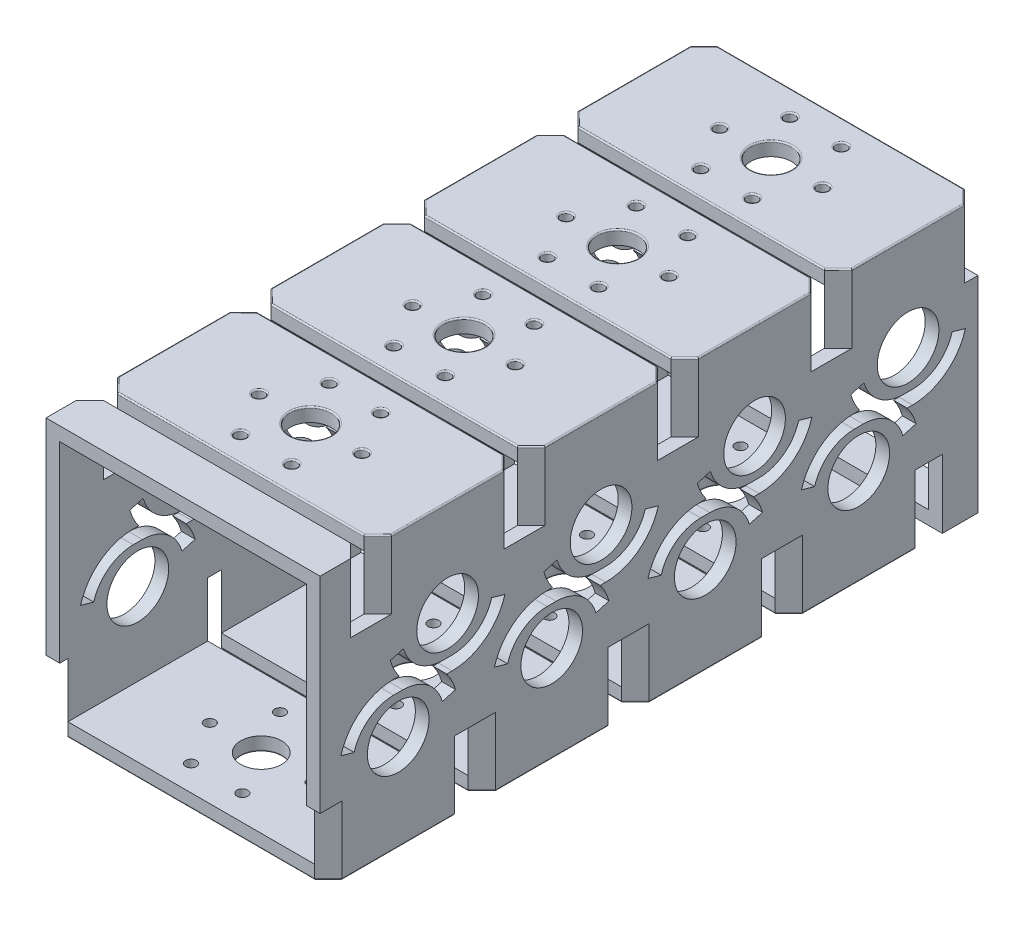
from build123d import *

# Parameters (mm, degrees)
SKETCH1_W           = 127
SKETCH1_H           = 127
SKETCH1_W_2         = 114.3
SKETCH1_H_2         = 114.3
BOSS_EXTRUDE1_DEPTH = 304.8
SKETCH2_W           = 127
SKETCH2_H           = 6.35
CUT_EXTRUDE1_DEPTH  = 31.75
CUT_EXTRUDE2_DEPTH  = 31.75
SKETCH5_R           = 14.2875
CUT_EXTRUDE4_DEPTH  = 128
LPATTERN2_COUNT     = 4
LPATTERN2_PITCH     = 71.12
LPATTERN3_COUNT     = 4
LPATTERN3_PITCH     = 71.12
CUT_EXTRUDE5_DEPTH  = 31.75
CUT_EXTRUDE6_DEPTH  = 31.75
LPATTERN4_COUNT     = 4
LPATTERN4_PITCH     = 71.12
SKETCH8_R           = 2.4892
SKETCH8_R_2         = 9.4869
CUT_EXTRUDE7_DEPTH  = 6.35
LPATTERN5_COUNT     = 4
LPATTERN5_PITCH     = 71.12
SKETCH9_R           = 2.4892
SKETCH9_R_2         = 9.4869
CUT_EXTRUDE8_DEPTH  = 6.35
SKETCH10_W          = 127
SKETCH10_H          = 6.35
CUT_EXTRUDE9_DEPTH  = 31.75
CUT_EXTRUDE10_DEPTH = 31.75
CUT_EXTRUDE11_DEPTH = 128
CUT_EXTRUDE12_DEPTH = 128
FILLET1_R           = 0.635


with BuildPart() as part:
    # Sketch1 → Boss-Extrude1 (new body)
    with BuildSketch(Plane.XY):
        with Locations((63.5, 63.5)):
            Rectangle(SKETCH1_W, SKETCH1_H)
        with Locations((63.5, 63.5)):
            Rectangle(SKETCH1_W_2, SKETCH1_H_2, mode=Mode.SUBTRACT)
    extrude(amount=BOSS_EXTRUDE1_DEPTH)

    # Sketch2 → Cut-Extrude1 (cut)
    with BuildSketch(Plane(origin=(0, 127, 0), x_dir=(1, 0, 0), z_dir=(0, 1, 0))):
        with Locations((63.5, -67.945)):
            Rectangle(SKETCH2_W, SKETCH2_H)
    cut_extrude1 = extrude(amount=-CUT_EXTRUDE1_DEPTH, mode=Mode.SUBTRACT)

    # Sketch3 → Cut-Extrude2 (cut)
    with BuildSketch(Plane(origin=(0, 127, 0), x_dir=(1, 0, 0), z_dir=(0, 1, 0))):
        Polygon((0, -58.42), (6.35, -64.77), (0, -64.77), align=None)
        Polygon((6.35, -71.12), (0, -77.47), (0, -71.12), align=None)
    cut_extrude2 = extrude(amount=-CUT_EXTRUDE2_DEPTH, mode=Mode.SUBTRACT)

    # Sketch5 → Cut-Extrude4 (cut, through all)
    with BuildSketch(Plane.ZY):
        with Locations((55.245, 44.45)):
            Circle(SKETCH5_R)
        with Locations((32.385, 82.55)):
            Circle(SKETCH5_R)
        with Locations((103.505, 82.55)):
            Circle(SKETCH5_R)
        with Locations((174.625, 82.55)):
            Circle(SKETCH5_R)
        with Locations((245.745, 82.55)):
            Circle(SKETCH5_R)
        with Locations((126.365, 44.45)):
            Circle(SKETCH5_R)
        with Locations((197.485, 44.45)):
            Circle(SKETCH5_R)
        with Locations((268.605, 44.45)):
            Circle(SKETCH5_R)
    extrude(amount=-CUT_EXTRUDE4_DEPTH, mode=Mode.SUBTRACT)

    # LPattern2: Cut-Extrude1 ×4
    with Locations(*[(0, 0, i * LPATTERN2_PITCH) for i in range(1, LPATTERN2_COUNT)]):
        add(cut_extrude1, mode=Mode.SUBTRACT)

    # LPattern3: Cut-Extrude2 ×4
    with Locations(*[(0, 0, i * LPATTERN3_PITCH) for i in range(1, LPATTERN3_COUNT)]):
        add(cut_extrude2, mode=Mode.SUBTRACT)

    # Sketch6 → Cut-Extrude5 (cut)
    with BuildSketch(Plane(origin=(0, 127, 0), x_dir=(1, 0, 0), z_dir=(0, 1, 0))):
        Polygon((6.35, 0), (0, -6.35), (0, 0), align=None)
        Polygon((127, -6.35), (120.65, 0), (127, 0), align=None)
    extrude(amount=-CUT_EXTRUDE5_DEPTH, mode=Mode.SUBTRACT)

    # Sketch7 → Cut-Extrude6 (cut)
    with BuildSketch(Plane(origin=(0, 127, 0), x_dir=(1, 0, 0), z_dir=(0, 1, 0))):
        Polygon((127, -77.47), (120.65, -71.12), (127, -71.12), align=None)
        Polygon((120.65, -64.77), (127, -58.42), (127, -64.77), align=None)
    cut_extrude6 = extrude(amount=-CUT_EXTRUDE6_DEPTH, mode=Mode.SUBTRACT)

    # LPattern4: Cut-Extrude6 ×4
    with Locations(*[(0, 0, i * LPATTERN4_PITCH) for i in range(1, LPATTERN4_COUNT)]):
        add(cut_extrude6, mode=Mode.SUBTRACT)

    # Sketch8 → Cut-Extrude7 (cut)
    with BuildSketch(Plane(origin=(0, 127, 0), x_dir=(1, 0, 0), z_dir=(0, 1, 0))):
        with Locations((87.3125, -32.385)):
            Circle(SKETCH8_R)
        with Locations((75.40625, -53.007229928)):
            Circle(SKETCH8_R)
        with Locations((51.59375, -53.007229928)):
            Circle(SKETCH8_R)
        with Locations((39.6875, -32.385)):
            Circle(SKETCH8_R)
        with Locations((51.59375, -11.762770072)):
            Circle(SKETCH8_R)
        with Locations((75.40625, -11.762770072)):
            Circle(SKETCH8_R)
        with Locations((63.5, -32.385)):
            Circle(SKETCH8_R_2)
    cut_extrude7 = extrude(amount=-CUT_EXTRUDE7_DEPTH, mode=Mode.SUBTRACT)

    # LPattern5: Cut-Extrude7 ×4
    with Locations(*[(0, 0, i * LPATTERN5_PITCH) for i in range(1, LPATTERN5_COUNT)]):
        add(cut_extrude7, mode=Mode.SUBTRACT)

    # Sketch9 → Cut-Extrude8 (cut)
    with BuildSketch(Plane.XZ):
        with Locations((51.59375, 34.622770072)):
            Circle(SKETCH9_R)
        with Locations((39.6875, 55.245)):
            Circle(SKETCH9_R)
        with Locations((51.59375, 75.867229928)):
            Circle(SKETCH9_R)
        with Locations((75.40625, 75.867229928)):
            Circle(SKETCH9_R)
        with Locations((87.3125, 55.245)):
            Circle(SKETCH9_R)
        with Locations((75.40625, 34.622770072)):
            Circle(SKETCH9_R)
        with Locations((63.5, 55.245)):
            Circle(SKETCH9_R_2)
        with Locations((51.59375, 105.742770072)):
            Circle(SKETCH9_R)
        with Locations((39.6875, 126.365)):
            Circle(SKETCH9_R)
        with Locations((51.59375, 146.987229928)):
            Circle(SKETCH9_R)
        with Locations((75.40625, 146.987229928)):
            Circle(SKETCH9_R)
        with Locations((87.3125, 126.365)):
            Circle(SKETCH9_R)
        with Locations((75.40625, 105.742770072)):
            Circle(SKETCH9_R)
        with Locations((63.5, 126.365)):
            Circle(SKETCH9_R_2)
        with Locations((51.59375, 176.862770072)):
            Circle(SKETCH9_R)
        with Locations((39.6875, 197.485)):
            Circle(SKETCH9_R)
        with Locations((51.59375, 218.107229928)):
            Circle(SKETCH9_R)
        with Locations((75.40625, 218.107229928)):
            Circle(SKETCH9_R)
        with Locations((87.3125, 197.485)):
            Circle(SKETCH9_R)
        with Locations((75.40625, 176.862770072)):
            Circle(SKETCH9_R)
        with Locations((63.5, 197.485)):
            Circle(SKETCH9_R_2)
        with Locations((51.59375, 247.982770072)):
            Circle(SKETCH9_R)
        with Locations((39.6875, 268.605)):
            Circle(SKETCH9_R)
        with Locations((51.59375, 289.227229928)):
            Circle(SKETCH9_R)
        with Locations((75.40625, 289.227229928)):
            Circle(SKETCH9_R)
        with Locations((87.3125, 268.605)):
            Circle(SKETCH9_R)
        with Locations((75.40625, 247.982770072)):
            Circle(SKETCH9_R)
        with Locations((63.5, 268.605)):
            Circle(SKETCH9_R_2)
    extrude(amount=-CUT_EXTRUDE8_DEPTH, mode=Mode.SUBTRACT)

    # Sketch10 → Cut-Extrude9 (cut)
    with BuildSketch(Plane.XZ):
        with Locations((63.5, 19.685)):
            Rectangle(SKETCH10_W, SKETCH10_H)
        with Locations((63.5, 90.805)):
            Rectangle(SKETCH10_W, SKETCH10_H)
        with Locations((63.5, 161.925)):
            Rectangle(SKETCH10_W, SKETCH10_H)
        with Locations((63.5, 233.045)):
            Rectangle(SKETCH10_W, SKETCH10_H)
        with Locations((63.5, 304.165)):
            Rectangle(SKETCH10_W, SKETCH10_H)
    extrude(amount=-CUT_EXTRUDE9_DEPTH, mode=Mode.SUBTRACT)

    # Sketch11 → Cut-Extrude10 (cut)
    with BuildSketch(Plane.XZ):
        Polygon((120.65, 22.86), (127, 29.21), (127, 22.86), align=None)
        Polygon((127, 81.28), (120.65, 87.63), (127, 87.63), align=None)
        Polygon((6.35, 87.63), (0, 81.28), (0, 87.63), align=None)
        Polygon((0, 29.21), (6.35, 22.86), (0, 22.86), align=None)
        Polygon((120.65, 93.98), (127, 100.33), (127, 93.98), align=None)
        Polygon((127, 152.4), (120.65, 158.75), (127, 158.75), align=None)
        Polygon((6.35, 158.75), (0, 152.4), (0, 158.75), align=None)
        Polygon((0, 100.33), (6.35, 93.98), (0, 93.98), align=None)
        Polygon((120.65, 165.1), (127, 171.45), (127, 165.1), align=None)
        Polygon((127, 223.52), (120.65, 229.87), (127, 229.87), align=None)
        Polygon((6.35, 229.87), (0, 223.52), (0, 229.87), align=None)
        Polygon((0, 171.45), (6.35, 165.1), (0, 165.1), align=None)
        Polygon((120.65, 236.22), (127, 242.57), (127, 236.22), align=None)
        Polygon((127, 294.64), (120.65, 300.99), (127, 300.99), align=None)
        Polygon((6.35, 300.99), (0, 294.64), (0, 300.99), align=None)
        Polygon((0, 242.57), (6.35, 236.22), (0, 236.22), align=None)
    extrude(amount=-CUT_EXTRUDE10_DEPTH, mode=Mode.SUBTRACT)

    # Sketch12 → Cut-Extrude11 (cut, through all)
    with BuildSketch(Plane(origin=(127, 0, 0), x_dir=(0, 0, -1), z_dir=(1, 0, 0))):
        with BuildLine():
            Line((-53.126893721, 62.23), (-57.363106279, 62.23))
            ThreePointArc((-57.363106279, 62.23), (-68.846345386, 58.379924987), (-75.687974839, 48.385928568))
            Line((-75.687974839, 48.385928568), (-81.796264359, 50.121238091))
            ThreePointArc((-81.796264359, 50.121238091), (-72.674091755, 63.446566649), (-57.363106279, 68.58))
            Line((-57.363106279, 68.58), (-53.126893721, 68.58))
            ThreePointArc((-53.126893721, 68.58), (-37.815908245, 63.446566649), (-28.693735641, 50.121238091))
            Line((-28.693735641, 50.121238091), (-34.802025161, 48.385928568))
            ThreePointArc((-34.802025161, 48.385928568), (-41.643654614, 58.379924987), (-53.126893721, 62.23))
        make_face()
        with BuildLine():
            Line((-146.807974839, 48.385928568), (-152.916264359, 50.121238091))
            ThreePointArc((-152.916264359, 50.121238091), (-143.794091755, 63.446566649), (-128.483106279, 68.58))
            Line((-128.483106279, 68.58), (-124.246893721, 68.58))
            ThreePointArc((-124.246893721, 68.58), (-108.935908245, 63.446566649), (-99.813735641, 50.121238091))
            Line((-99.813735641, 50.121238091), (-105.922025161, 48.385928568))
            ThreePointArc((-105.922025161, 48.385928568), (-112.763654614, 58.379924987), (-124.246893721, 62.23))
            Line((-124.246893721, 62.23), (-128.483106279, 62.23))
            ThreePointArc((-128.483106279, 62.23), (-139.966345386, 58.379924987), (-146.807974839, 48.385928568))
        make_face()
        with BuildLine():
            Line((-217.927974839, 48.385928568), (-224.036264359, 50.121238091))
            ThreePointArc((-224.036264359, 50.121238091), (-214.914091755, 63.446566649), (-199.603106279, 68.58))
            Line((-199.603106279, 68.58), (-195.366893721, 68.58))
            ThreePointArc((-195.366893721, 68.58), (-180.055908245, 63.446566649), (-170.933735641, 50.121238091))
            Line((-170.933735641, 50.121238091), (-177.042025161, 48.385928568))
            ThreePointArc((-177.042025161, 48.385928568), (-183.883654614, 58.379924987), (-195.366893721, 62.23))
            Line((-195.366893721, 62.23), (-199.603106279, 62.23))
            ThreePointArc((-199.603106279, 62.23), (-211.086345386, 58.379924987), (-217.927974839, 48.385928568))
        make_face()
        with BuildLine():
            Line((-289.047974839, 48.385928568), (-295.156264359, 50.121238091))
            ThreePointArc((-295.156264359, 50.121238091), (-286.034091755, 63.446566649), (-270.723106279, 68.58))
            Line((-270.723106279, 68.58), (-266.486893721, 68.58))
            ThreePointArc((-266.486893721, 68.58), (-251.175908245, 63.446566649), (-242.053735641, 50.121238091))
            Line((-242.053735641, 50.121238091), (-248.162025161, 48.385928568))
            ThreePointArc((-248.162025161, 48.385928568), (-255.003654614, 58.379924987), (-266.486893721, 62.23))
            Line((-266.486893721, 62.23), (-270.723106279, 62.23))
            ThreePointArc((-270.723106279, 62.23), (-282.206345386, 58.379924987), (-289.047974839, 48.385928568))
        make_face()
    extrude(amount=-CUT_EXTRUDE11_DEPTH, mode=Mode.SUBTRACT)

    # Sketch13 → Cut-Extrude12 (cut, through all)
    with BuildSketch(Plane(origin=(127, 0, 0), x_dir=(0, 0, -1), z_dir=(1, 0, 0))):
        with BuildLine():
            Line((-34.503106279, 64.77), (-30.266893721, 64.77))
            ThreePointArc((-30.266893721, 64.77), (-18.783654614, 68.620075013), (-11.942025161, 78.614071432))
            Line((-11.942025161, 78.614071432), (-5.833735641, 76.878761909))
            ThreePointArc((-5.833735641, 76.878761909), (-14.955908245, 63.553433351), (-30.266893721, 58.42))
            Line((-30.266893721, 58.42), (-34.503106279, 58.42))
            ThreePointArc((-34.503106279, 58.42), (-49.814091755, 63.553433351), (-58.936264359, 76.878761909))
            Line((-58.936264359, 76.878761909), (-52.827974839, 78.614071432))
            ThreePointArc((-52.827974839, 78.614071432), (-45.986345386, 68.620075013), (-34.503106279, 64.77))
        make_face()
        with BuildLine():
            Line((-123.947974839, 78.614071432), (-130.056264359, 76.878761909))
            ThreePointArc((-130.056264359, 76.878761909), (-120.934091755, 63.553433351), (-105.623106279, 58.42))
            Line((-105.623106279, 58.42), (-101.386893721, 58.42))
            ThreePointArc((-101.386893721, 58.42), (-86.075908245, 63.553433351), (-76.953735641, 76.878761909))
            Line((-76.953735641, 76.878761909), (-83.062025161, 78.614071432))
            ThreePointArc((-83.062025161, 78.614071432), (-89.903654614, 68.620075013), (-101.386893721, 64.77))
            Line((-101.386893721, 64.77), (-105.623106279, 64.77))
            ThreePointArc((-105.623106279, 64.77), (-117.106345386, 68.620075013), (-123.947974839, 78.614071432))
        make_face()
        with BuildLine():
            Line((-195.067974839, 78.614071432), (-201.176264359, 76.878761909))
            ThreePointArc((-201.176264359, 76.878761909), (-192.054091755, 63.553433351), (-176.743106279, 58.42))
            Line((-176.743106279, 58.42), (-172.506893721, 58.42))
            ThreePointArc((-172.506893721, 58.42), (-157.195908245, 63.553433351), (-148.073735641, 76.878761909))
            Line((-148.073735641, 76.878761909), (-154.182025161, 78.614071432))
            ThreePointArc((-154.182025161, 78.614071432), (-161.023654614, 68.620075013), (-172.506893721, 64.77))
            Line((-172.506893721, 64.77), (-176.743106279, 64.77))
            ThreePointArc((-176.743106279, 64.77), (-188.226345386, 68.620075013), (-195.067974839, 78.614071432))
        make_face()
        with BuildLine():
            Line((-266.187974839, 78.614071432), (-272.296264359, 76.878761909))
            ThreePointArc((-272.296264359, 76.878761909), (-263.174091755, 63.553433351), (-247.863106279, 58.42))
            Line((-247.863106279, 58.42), (-243.626893721, 58.42))
            ThreePointArc((-243.626893721, 58.42), (-228.315908245, 63.553433351), (-219.193735641, 76.878761909))
            Line((-219.193735641, 76.878761909), (-225.302025161, 78.614071432))
            ThreePointArc((-225.302025161, 78.614071432), (-232.143654614, 68.620075013), (-243.626893721, 64.77))
            Line((-243.626893721, 64.77), (-247.863106279, 64.77))
            ThreePointArc((-247.863106279, 64.77), (-259.346345386, 68.620075013), (-266.187974839, 78.614071432))
        make_face()
    extrude(amount=-CUT_EXTRUDE12_DEPTH, mode=Mode.SUBTRACT)

    # Fillet1
    fillet1_edges = [part.edges().sort_by_distance(p)[0] for p in [
        (63.5, 127, 142.24),
        (63.5, 127, 213.36),
        (0, 127, 103.505),
        (0, 127, 245.745),
        (0, 127, 174.625),
        (3.175, 127, 132.715),
        (3.175, 127, 145.415),
        (3.175, 127, 203.835),
        (3.175, 127, 216.535),
        (3.175, 127, 274.955),
        (63.5, 127, 0),
        (3.175, 127, 3.175),
        (123.825, 127, 3.175),
        (63.5, 127, 64.77),
        (127, 127, 32.385),
        (123.825, 127, 74.295),
        (123.825, 127, 61.595),
        (63.5, 127, 135.89),
        (63.5, 127, 207.01),
        (63.5, 127, 278.13),
        (127, 127, 103.505),
        (127, 127, 174.625),
        (127, 127, 245.745),
        (123.825, 127, 203.835),
        (123.825, 127, 216.535),
        (123.825, 127, 132.715),
        (123.825, 127, 274.955),
        (123.825, 127, 145.415),
        (84.8233, 127, 32.385),
        (37.1983, 127, 32.385),
        (49.10455, 127, 53.007229928),
        (72.91705, 127, 53.007229928),
        (54.0131, 127, 32.385),
        (49.10455, 127, 11.762770072),
        (72.91705, 127, 11.762770072),
        (72.91705, 127, 195.247229928),
        (49.10455, 127, 195.247229928),
        (37.1983, 127, 174.625),
        (49.10455, 127, 154.002770072),
        (72.91705, 127, 266.367229928),
        (54.0131, 127, 245.745),
        (84.8233, 127, 245.745),
        (72.91705, 127, 154.002770072),
        (37.1983, 127, 103.505),
        (49.10455, 127, 124.127229928),
        (72.91705, 127, 124.127229928),
        (54.0131, 127, 103.505),
        (49.10455, 127, 82.882770072),
        (72.91705, 127, 82.882770072),
        (84.8233, 127, 174.625),
        (54.0131, 127, 174.625),
        (49.10455, 127, 266.367229928),
        (37.1983, 127, 245.745),
        (49.10455, 127, 225.122770072),
        (72.91705, 127, 225.122770072),
        (84.8233, 127, 103.505),
        (49.10455, 0, 146.987229928),
        (72.91705, 0, 146.987229928),
        (84.8233, 0, 126.365),
        (72.91705, 0, 105.742770072),
        (54.0131, 0, 126.365),
        (49.10455, 0, 176.862770072),
        (37.1983, 0, 197.485),
        (49.10455, 0, 218.107229928),
        (37.1983, 0, 55.245),
        (49.10455, 0, 75.867229928),
        (72.91705, 0, 75.867229928),
        (84.8233, 0, 55.245),
        (72.91705, 0, 34.622770072),
        (54.0131, 0, 55.245),
        (49.10455, 0, 105.742770072),
        (37.1983, 0, 126.365),
        (84.8233, 0, 268.605),
        (72.91705, 0, 247.982770072),
        (54.0131, 0, 268.605),
        (72.91705, 0, 289.227229928),
        (49.10455, 0, 289.227229928),
        (37.1983, 0, 268.605),
        (49.10455, 0, 247.982770072),
        (72.91705, 0, 218.107229928),
        (84.8233, 0, 197.485),
        (72.91705, 0, 176.862770072),
        (54.0131, 0, 197.485),
        (49.10455, 0, 34.622770072),
        (63.5, 127, 71.12),
        (0, 127, 32.385),
        (3.175, 127, 61.595),
        (63.5, 0, 22.86),
        (63.5, 0, 93.98),
        (63.5, 0, 87.63),
        (63.5, 0, 165.1),
        (63.5, 0, 158.75),
        (3.175, 127, 74.295),
        (63.5, 0, 236.22),
        (63.5, 0, 229.87),
        (63.5, 0, 300.99),
        (127, 0, 268.605),
        (127, 0, 197.485),
        (127, 0, 126.365),
        (127, 0, 55.245),
        (0, 0, 268.605),
        (0, 0, 55.245),
        (0, 0, 126.365),
        (0, 0, 197.485),
        (123.825, 0, 155.575),
        (3.175, 0, 155.575),
        (3.175, 0, 97.155),
        (123.825, 0, 168.275),
        (123.825, 0, 84.455),
        (3.175, 0, 84.455),
        (3.175, 0, 26.035),
        (123.825, 0, 97.155),
        (3.175, 0, 239.395),
        (3.175, 0, 297.815),
        (123.825, 0, 297.815),
        (123.825, 0, 226.695),
        (3.175, 0, 226.695),
        (3.175, 0, 168.275),
        (123.825, 0, 239.395),
        (123.825, 0, 26.035),
    ]]
    fillet(fillet1_edges, radius=FILLET1_R)


solid = part.part
